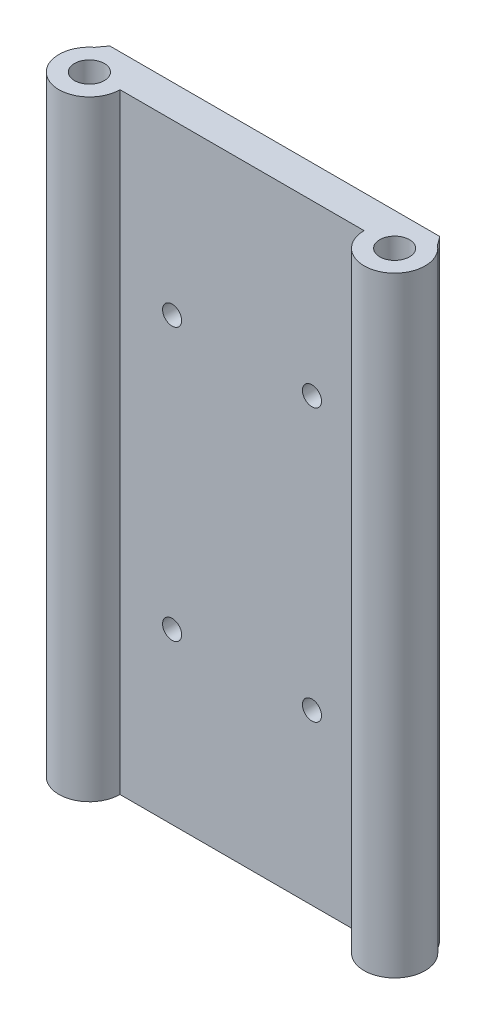
from build123d import *

# Parameters (mm, degrees)
SKETCH1_R               = 4.9609375
BOSS_EXTRUDE1_DEPTH     = 101.6
SKETCH2_R               = 3.175
CUT_EXTRUDE1_DEPTH      = 11.16
CUT_EXTRUDE1_DEPTH_BACK = 11.914472708


with BuildPart() as part:
    # Sketch1 → Boss-Extrude1 (new body, symmetric)
    with BuildSketch(Plane(origin=(0, 0, 0), x_dir=(1, 0, 0), z_dir=(0, 1, 0))):
        with BuildLine():
            ThreePointArc((-54.898232946, 10.914472708), (-55.979756859, 9.486084273), (-57.024125462, 8.030308975))
            ThreePointArc((-57.024125462, 8.030308975), (-55.271492218, -9.123122127), (-40.64, 0))
            Line((-40.64, 0), (40.64, 0))
            ThreePointArc((40.64, 0), (55.271492218, -9.123122127), (57.024125462, 8.030308975))
            ThreePointArc((57.024125462, 8.030308975), (55.979756859, 9.486084273), (54.898232946, 10.914472708))
            Line((54.898232946, 10.914472708), (-54.898232946, 10.914472708))
        make_face()
        with Locations((-50.8, 0)):
            Circle(SKETCH1_R, mode=Mode.SUBTRACT)
        with Locations((50.8, 0)):
            Circle(SKETCH1_R, mode=Mode.SUBTRACT)
    extrude(amount=BOSS_EXTRUDE1_DEPTH, both=True)

    # Sketch2 → Cut-Extrude1 (cut, two sides)
    with BuildSketch(Plane.XY) as cut_extrude1_sk:
        with Locations((-23.278917925, 45.299515962)):
            Circle(SKETCH2_R)
        with Locations((23.278917925, 45.299515962)):
            Circle(SKETCH2_R)
        with Locations((23.278917925, -45.299515962)):
            Circle(SKETCH2_R)
        with Locations((-23.278917925, -45.299515962)):
            Circle(SKETCH2_R)
    extrude(amount=CUT_EXTRUDE1_DEPTH, mode=Mode.SUBTRACT)
    extrude(cut_extrude1_sk.sketch, amount=-CUT_EXTRUDE1_DEPTH_BACK, mode=Mode.SUBTRACT)


solid = part.part
